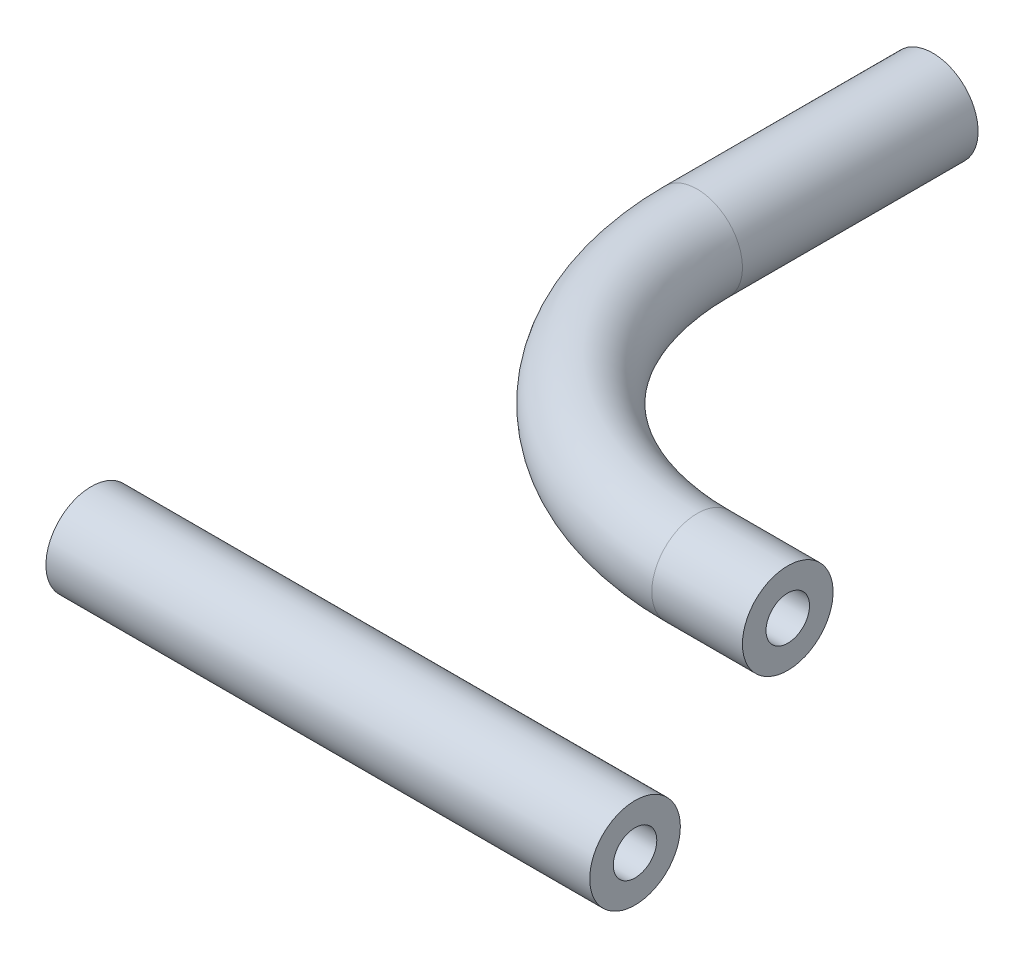
from build123d import *

# Parameters (mm, degrees)
SKETCH2_R           = 3.175
SKETCH2_R_2         = 1.524
SKETCH3_R           = 3.175
SKETCH3_R_2         = 1.524
BOSS_EXTRUDE1_DEPTH = 38.1


with BuildPart() as part:
    # Sweep1: sweep along a path in Sketch1
    with BuildLine(Plane(origin=(0, 0, 0), x_dir=(1, 0, 0), z_dir=(0, 1, 0))) as sweep1_path:
        Line((0, 39.37), (0, 22.86))
        ThreePointArc((0, 22.86), (6.695538982, 6.695538982), (22.86, 0))
        Line((22.86, 0), (29.21, 0))
    # Sketch2 → Sweep1 (sweep)
    with BuildSketch(Plane.ZY.offset(-29.21)):
        with Locations((-3.175, 0)):
            Circle(SKETCH2_R)
        with Locations((-3.175, 0)):
            Circle(SKETCH2_R_2, mode=Mode.SUBTRACT)
    sweep(path=sweep1_path.line)


with BuildPart() as body_2:
    # Sketch3 → Boss-Extrude1 (new body)
    with BuildSketch(Plane(origin=(0, 0, 0), x_dir=(0, 0, -1), z_dir=(1, 0, 0))):
        with Locations((-16.414544802, 0)):
            Circle(SKETCH3_R)
        with Locations((-16.414544802, 0)):
            Circle(SKETCH3_R_2, mode=Mode.SUBTRACT)
    extrude(amount=BOSS_EXTRUDE1_DEPTH)


solid = Compound([part.part, body_2.part])
